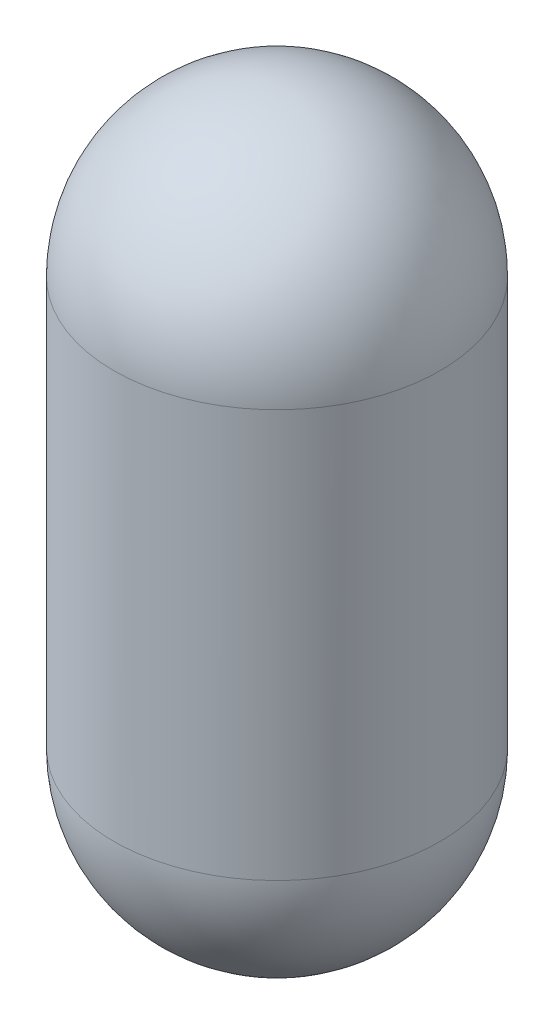
from build123d import *

# Parameters (mm, degrees)
SKETCH1_R           = 40
BOSS_EXTRUDE1_DEPTH = 100
SKETCH2_R           = 15
CUT_EXTRUDE1_DEPTH  = 5
BOSS_EXTRUDE2_DEPTH = 5
SKETCH4_R           = 2.5
CUT_EXTRUDE2_DEPTH  = 5


with BuildPart() as part:
    # Sketch1 → Boss-Extrude1 (new body)
    with BuildSketch(Plane(origin=(0, 0, 0), x_dir=(1, 0, 0), z_dir=(0, 1, 0))):
        Circle(SKETCH1_R)
        with BuildLine():
            Line((-2.5, 34.910600109), (-2.5, -34.910600109))
            ThreePointArc((-2.5, -34.910600109), (-35, 0), (-2.5, 34.910600109))
        make_face(mode=Mode.SUBTRACT)
        with BuildLine():
            Line((2.5, 34.910600109), (2.5, -34.910600109))
            ThreePointArc((2.5, -34.910600109), (35, 0), (2.5, 34.910600109))
        make_face(mode=Mode.SUBTRACT)
    extrude(amount=-BOSS_EXTRUDE1_DEPTH)

    # Sketch2 → Cut-Extrude1 (cut)
    with BuildSketch(Plane(origin=(2.5, 0, 0), x_dir=(0, 0, -1), z_dir=(1, 0, 0))):
        with Locations((0, -75)):
            Circle(SKETCH2_R)
    extrude(amount=-CUT_EXTRUDE1_DEPTH, mode=Mode.SUBTRACT)

    # Sketch3 → Revolve1 (revolve)
    with BuildSketch(Plane(origin=(0, 0, 0), x_dir=(0, 0, -1), z_dir=(1, 0, 0))):
        with BuildLine():
            Line((35, -100), (40, -100))
            ThreePointArc((40, -100), (28.284271247, -128.284271247), (0, -140))
            Line((0, -140), (0, -135))
            ThreePointArc((0, -135), (24.748737342, -124.748737342), (35, -100))
        make_face()
    revolve1 = revolve(axis=Axis((0, -140, 0), (0, 1, 0)))

    # Sketch1_2 → Boss-Extrude2 (add)
    with BuildSketch(Plane(origin=(0, 0, 0), x_dir=(1, 0, 0), z_dir=(0, 1, 0))):
        with BuildLine():
            Line((-2.5, -34.910600109), (-2.5, 34.910600109))
            ThreePointArc((-2.5, 34.910600109), (-35, 0), (-2.5, -34.910600109))
        make_face()
        with BuildLine():
            ThreePointArc((2.5, -34.910600109), (35, 0), (2.5, 34.910600109))
            Line((2.5, 34.910600109), (2.5, -34.910600109))
        make_face()
    extrude(amount=-BOSS_EXTRUDE2_DEPTH)

    # Sketch4 → Cut-Extrude2 (cut)
    with BuildSketch(Plane(origin=(0, 0, 0), x_dir=(1, 0, 0), z_dir=(0, 1, 0))):
        with Locations((-15, 0)):
            Circle(SKETCH4_R)
        with Locations((15, 0)):
            Circle(SKETCH4_R)
    extrude(amount=-CUT_EXTRUDE2_DEPTH, mode=Mode.SUBTRACT)

    # Mirror1: Revolve1 across plane
    add(revolve1.mirror(Plane.ZX.offset(-50)))


solid = part.part
